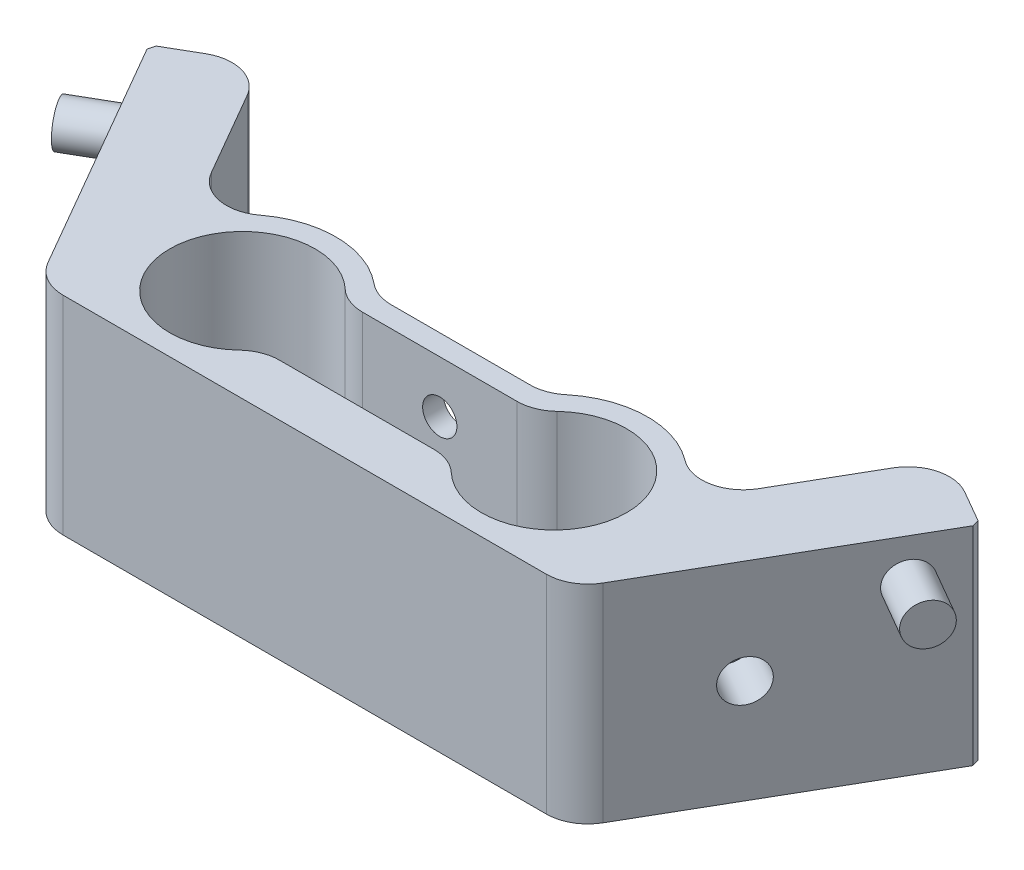
from build123d import *

# Parameters (mm, degrees)
EXTRUDE_1_DEPTH     = 20
SKETCH_2_R          = 7
CUT_EXTRUDE_1_DEPTH = 21
SKETCH_3_W          = 30
SKETCH_3_H          = 8
CUT_EXTRUDE_2_DEPTH = 21
FILLET_1_R          = 4
CHAMFER_1_SIZE      = 0.5
M4X0_71_D           = 3.3
M4X0_71_DEPTH       = 13.5
M4X0_71_TIP         = 0.991420021
SKETCH_6_R          = 2
CUT_EXTRUDE_3_DEPTH = 5
SKETCH_7_R          = 2
CUT_EXTRUDE_4_DEPTH = 5
SKETCH_8_R          = 2
EXTRUDE_2_DEPTH     = 5
SKETCH_9_R          = 2
EXTRUDE_3_DEPTH     = 5


with BuildPart() as part:
    # Эскиз1 → Бобышка-Вытянуть1 (new body)
    with BuildSketch(Plane(origin=(0, 0, 0), x_dir=(1, 0, 0), z_dir=(0, 1, 0))):
        with BuildLine():
            Line((0, 0), (14.43375673, -25))
            Line((14.43375673, -25), (65.56624327, -25))
            Line((65.56624327, -25), (80, 0))
            Line((80, 0), (73.07179677, 4))
            Line((73.07179677, 4), (63.396104176, -12.758791171))
            ThreePointArc((63.396104176, -12.758791171), (56.617091212, -7.146468727), (48.291796068, -10))
            Line((48.291796068, -10), (31.708203932, -10))
            ThreePointArc((31.708203932, -10), (23.382908788, -7.146468727), (16.603895824, -12.758791171))
            Line((16.603895824, -12.758791171), (6.92820323, 4))
            Line((6.92820323, 4), (0, 0))
        make_face()
    extrude(amount=EXTRUDE_1_DEPTH)

    # Эскиз2 → Вырез-Вытянуть1 (cut, through all)
    with BuildSketch(Plane(origin=(0, 20, 0), x_dir=(1, 0, 0), z_dir=(0, 1, 0))):
        with Locations((25, -16)):
            Circle(SKETCH_2_R)
        with Locations((55, -16)):
            Circle(SKETCH_2_R)
    extrude(amount=-CUT_EXTRUDE_1_DEPTH, mode=Mode.SUBTRACT)

    # Эскиз3 → Вырез-Вытянуть2 (cut, through all)
    with BuildSketch(Plane(origin=(0, 20, 0), x_dir=(1, 0, 0), z_dir=(0, 1, 0))):
        with Locations((40, -16)):
            Rectangle(SKETCH_3_W, SKETCH_3_H)
    extrude(amount=-CUT_EXTRUDE_2_DEPTH, mode=Mode.SUBTRACT)

    # Скругление1
    fillet_1_edges = [part.edges().sort_by_distance(p)[0] for p in [
        (6.92820323, 10, -4),
        (16.603895824, 10, 12.758791171),
        (31.708203932, 10, 10),
        (48.291796068, 10, 10),
        (63.396104176, 10, 12.758791171),
        (73.07179677, 10, -4),
        (65.56624327, 10, 25),
        (14.43375673, 10, 25),
        (49.255437353, 10, 12),
        (49.255437353, 10, 20),
        (30.744562647, 10, 20),
        (30.744562647, 10, 12),
    ]]
    fillet(fillet_1_edges, radius=FILLET_1_R)

    # Фаска1
    chamfer_1_edges = [part.edges().sort_by_distance(p)[0] for p in [
        (80, 10, 0),
        (0, 10, 0),
    ]]
    chamfer(chamfer_1_edges, length=CHAMFER_1_SIZE)

    # Отверстие обработанное метчиком M4x0.71
    with Locations(Plane(origin=(40, 5, 10), x_dir=(-1, 0, 0), z_dir=(0, 0, -1))):
        with Locations((0, 0), (0, 10)):
            Hole(M4X0_71_D / 2, depth=M4X0_71_DEPTH)
            with Locations((0, 0, -(M4X0_71_DEPTH + M4X0_71_TIP / 2))):  # 118° drill point
                Cone(0, M4X0_71_D / 2, M4X0_71_TIP, mode=Mode.SUBTRACT)

    # Эскиз6 → Вырез-Вытянуть3 (cut)
    with BuildSketch(Plane(origin=(60, 0, 34.641016151), x_dir=(0.5, 0, -0.866025404), z_dir=(0.866025404, 0, 0.5))):
        with Locations((23.441887617, 10)):
            Circle(SKETCH_6_R)
    extrude(amount=-CUT_EXTRUDE_3_DEPTH, mode=Mode.SUBTRACT)

    # Эскиз7 → Вырез-Вытянуть4 (cut)
    with BuildSketch(Plane(origin=(0, 0, 0), x_dir=(0.5, 0, 0.866025404), z_dir=(-0.866025404, 0, 0.5))):
        with Locations((16.558112383, 10)):
            Circle(SKETCH_7_R)
    extrude(amount=-CUT_EXTRUDE_4_DEPTH, mode=Mode.SUBTRACT)

    # Эскиз8 → Бобышка-Вытянуть2 (add)
    with BuildSketch(Plane(origin=(0, 0, 0), x_dir=(0.5, 0, 0.866025404), z_dir=(-0.866025404, 0, 0.5))):
        with Locations((5, 16)):
            Circle(SKETCH_8_R)
    extrude(amount=EXTRUDE_2_DEPTH)

    # Эскиз9 → Бобышка-Вытянуть3 (add)
    with BuildSketch(Plane(origin=(60, 0, 34.641016151), x_dir=(0.5, 0, -0.866025404), z_dir=(0.866025404, 0, 0.5))):
        with Locations((35, 16)):
            Circle(SKETCH_9_R)
    extrude(amount=EXTRUDE_3_DEPTH)


solid = part.part
